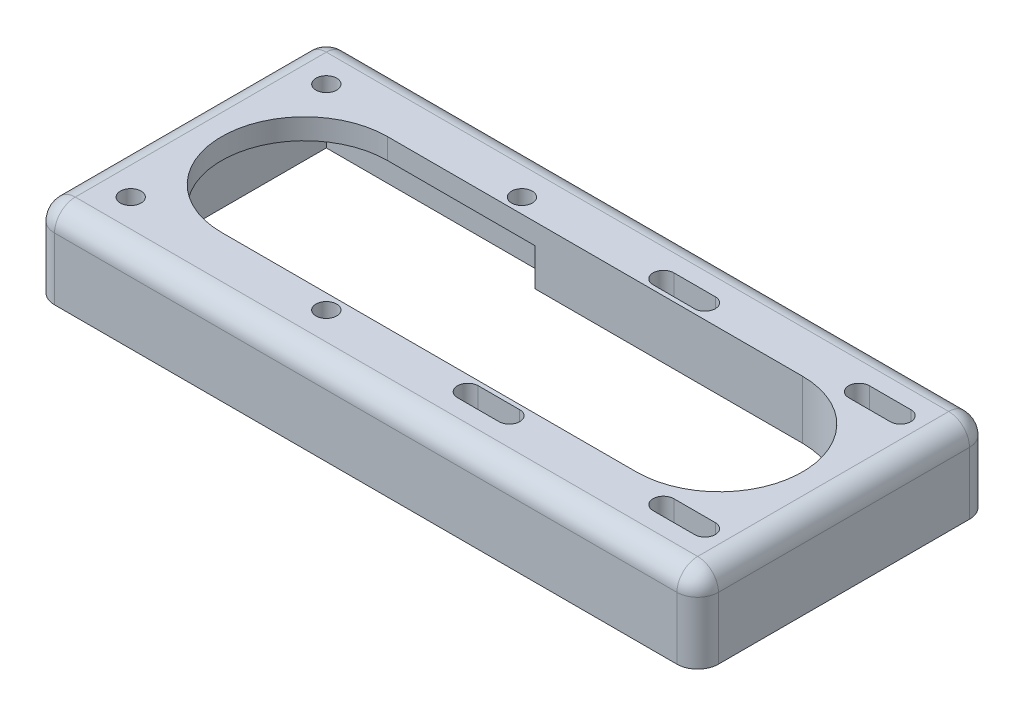
from build123d import *

# Parameters (mm, degrees)
SKETCH2_R           = 2.5
SKETCH2_W           = 67
SKETCH2_H           = 1.75
BOSS_EXTRUDE1_DEPTH = 5
SKETCH4_W           = 160
SKETCH4_H           = 70.5
SKETCH4_W_2         = 150
SKETCH4_H_2         = 60.5
BOSS_EXTRUDE2_DEPTH = 20
SKETCH5_W           = 22.5
SKETCH5_H           = 10.25
BOSS_EXTRUDE3_DEPTH = 9
FILLET2_R           = 5


with BuildPart() as part:
    # Sketch2 → Boss-Extrude1 (new body)
    with BuildSketch(Plane(origin=(0, 0, 0), x_dir=(1, 0, 0), z_dir=(0, 1, 0))):
        with BuildLine():
            Line((-14.5, 30.25), (-75, 30.25))
            Line((-75, 30.25), (-75, -30.25))
            Line((-75, -30.25), (-14.5, -30.25))
            Line((-14.5, -30.25), (-14.5, -20))
            Line((-14.5, -20), (-50, -20))
            ThreePointArc((-50, -20), (-70, 0), (-50, 20))
            Line((-50, 20), (-14.5, 20))
            Line((-14.5, 20), (-14.5, 30.25))
        make_face()
        with Locations((-68.32, -23.57)):
            Circle(SKETCH2_R, mode=Mode.SUBTRACT)
        with Locations((-21.18, -23.57)):
            Circle(SKETCH2_R, mode=Mode.SUBTRACT)
        with Locations((-68.32, 23.57)):
            Circle(SKETCH2_R, mode=Mode.SUBTRACT)
        with Locations((-21.18, 23.57)):
            Circle(SKETCH2_R, mode=Mode.SUBTRACT)
        with BuildLine():
            Line((8, 30.25), (-14.5, 30.25))
            Line((-14.5, 30.25), (-14.5, 20))
            Line((-14.5, 20), (50, 20))
            ThreePointArc((50, 20), (64.142135624, 14.142135624), (70, 0))
            ThreePointArc((70, 0), (64.142135624, -14.142135624), (50, -20))
            Line((50, -20), (-14.5, -20))
            Line((-14.5, -20), (-14.5, -30.25))
            Line((-14.5, -30.25), (8, -30.25))
            Line((8, -30.25), (8, -28.5))
            Line((8, -28.5), (75, -28.5))
            Line((75, -28.5), (75, 28.5))
            Line((75, 28.5), (8, 28.5))
            Line((8, 28.5), (8, 30.25))
        make_face()
        with BuildLine():
            ThreePointArc((25.43, -23.57), (24.697766953, -25.337766953), (22.93, -26.07))
            Line((22.93, -26.07), (12.93, -26.07))
            ThreePointArc((12.93, -26.07), (10.43, -23.57), (12.93, -21.07))
            Line((12.93, -21.07), (22.93, -21.07))
            ThreePointArc((22.93, -21.07), (24.697766953, -21.802233047), (25.43, -23.57))
        make_face(mode=Mode.SUBTRACT)
        with BuildLine():
            ThreePointArc((72.57, -23.57), (71.837766953, -25.337766953), (70.07, -26.07))
            Line((70.07, -26.07), (60.07, -26.07))
            ThreePointArc((60.07, -26.07), (57.57, -23.57), (60.07, -21.07))
            Line((60.07, -21.07), (70.07, -21.07))
            ThreePointArc((70.07, -21.07), (71.837766953, -21.802233047), (72.57, -23.57))
        make_face(mode=Mode.SUBTRACT)
        with BuildLine():
            ThreePointArc((25.43, 23.57), (24.697766953, 21.802233047), (22.93, 21.07))
            Line((22.93, 21.07), (12.93, 21.07))
            ThreePointArc((12.93, 21.07), (10.43, 23.57), (12.93, 26.07))
            Line((12.93, 26.07), (22.93, 26.07))
            ThreePointArc((22.93, 26.07), (24.697766953, 25.337766953), (25.43, 23.57))
        make_face(mode=Mode.SUBTRACT)
        with BuildLine():
            ThreePointArc((60.07, 21.07), (57.57, 23.57), (60.07, 26.07))
            Line((60.07, 26.07), (70.07, 26.07))
            ThreePointArc((70.07, 26.07), (71.837766953, 25.337766953), (72.57, 23.57))
            ThreePointArc((72.57, 23.57), (71.837766953, 21.802233047), (70.07, 21.07))
            Line((70.07, 21.07), (60.07, 21.07))
        make_face(mode=Mode.SUBTRACT)
        with Locations((41.5, -29.375)):
            Rectangle(SKETCH2_W, SKETCH2_H)
        with Locations((41.5, 29.375)):
            Rectangle(SKETCH2_W, SKETCH2_H)
    extrude(amount=BOSS_EXTRUDE1_DEPTH)

    # Sketch4 → Boss-Extrude2 (add)
    with BuildSketch(Plane(origin=(0, 5, 0), x_dir=(1, 0, 0), z_dir=(0, 1, 0))):
        Rectangle(SKETCH4_W, SKETCH4_H)
        Rectangle(SKETCH4_W_2, SKETCH4_H_2, mode=Mode.SUBTRACT)
    extrude(amount=-BOSS_EXTRUDE2_DEPTH)

    # Sketch5 → Boss-Extrude3 (add)
    with BuildSketch(Plane(origin=(0, 0, 0), x_dir=(-1, 0, 0), z_dir=(0, -1, 0))):
        with BuildLine():
            Line((-8, 20), (-8, 30.25))
            Line((-8, 30.25), (-75, 30.25))
            Line((-75, 30.25), (-75, -30.25))
            Line((-75, -30.25), (-8, -30.25))
            Line((-8, -30.25), (-8, -20))
            Line((-8, -20), (-50, -20))
            ThreePointArc((-50, -20), (-70, 0), (-50, 20))
            Line((-50, 20), (-8, 20))
        make_face()
        with BuildLine():
            ThreePointArc((-57.57, -23.57), (-58.302233047, -25.337766953), (-60.07, -26.07))
            Line((-60.07, -26.07), (-70.07, -26.07))
            ThreePointArc((-70.07, -26.07), (-72.57, -23.57), (-70.07, -21.07))
            Line((-70.07, -21.07), (-60.07, -21.07))
            ThreePointArc((-60.07, -21.07), (-58.302233047, -21.802233047), (-57.57, -23.57))
        make_face(mode=Mode.SUBTRACT)
        with BuildLine():
            ThreePointArc((-10.43, -23.57), (-11.162233047, -25.337766953), (-12.93, -26.07))
            Line((-12.93, -26.07), (-22.93, -26.07))
            ThreePointArc((-22.93, -26.07), (-25.43, -23.57), (-22.93, -21.07))
            Line((-22.93, -21.07), (-12.93, -21.07))
            ThreePointArc((-12.93, -21.07), (-11.162233047, -21.802233047), (-10.43, -23.57))
        make_face(mode=Mode.SUBTRACT)
        with BuildLine():
            ThreePointArc((-70.07, 21.07), (-72.57, 23.57), (-70.07, 26.07))
            Line((-70.07, 26.07), (-60.07, 26.07))
            ThreePointArc((-60.07, 26.07), (-58.302233047, 25.337766953), (-57.57, 23.57))
            ThreePointArc((-57.57, 23.57), (-58.302233047, 21.802233047), (-60.07, 21.07))
            Line((-60.07, 21.07), (-70.07, 21.07))
        make_face(mode=Mode.SUBTRACT)
        with BuildLine():
            ThreePointArc((-22.93, 21.07), (-25.43, 23.57), (-22.93, 26.07))
            Line((-22.93, 26.07), (-12.93, 26.07))
            ThreePointArc((-12.93, 26.07), (-11.162233047, 25.337766953), (-10.43, 23.57))
            ThreePointArc((-10.43, 23.57), (-11.162233047, 21.802233047), (-12.93, 21.07))
            Line((-12.93, 21.07), (-22.93, 21.07))
        make_face(mode=Mode.SUBTRACT)
        with Locations((3.25, 25.125)):
            Rectangle(SKETCH5_W, SKETCH5_H)
        with Locations((3.25, -25.125)):
            Rectangle(SKETCH5_W, SKETCH5_H)
    extrude(amount=BOSS_EXTRUDE3_DEPTH)

    # Fillet2
    fillet2_edges = [part.edges().sort_by_distance(p)[0] for p in [
        (-80, 5, 0),
        (0, 5, 35.25),
        (0, 5, -35.25),
        (-80, -5, -35.25),
        (80, 5, 0),
        (80, -5, -35.25),
        (80, -5, 35.25),
        (-80, -5, 35.25),
    ]]
    fillet(fillet2_edges, radius=FILLET2_R)


solid = part.part
